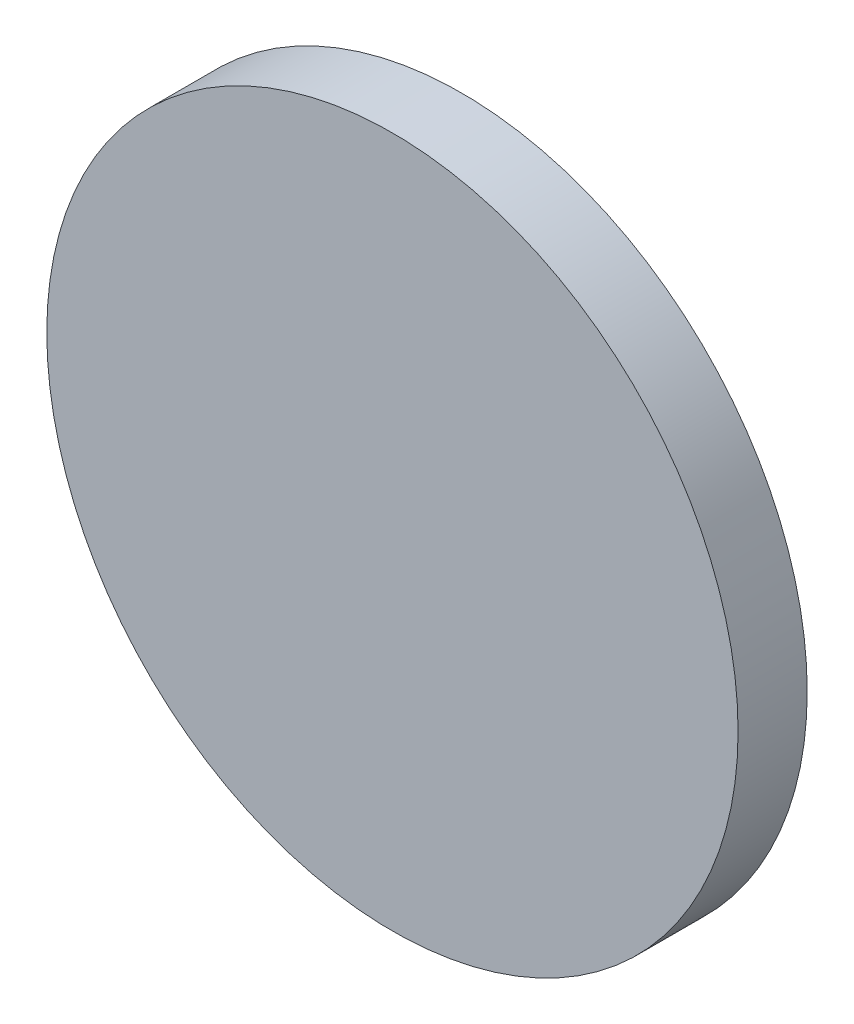
from build123d import *

# Parameters (mm, degrees)
SKETCH_1_R      = 15
EXTRUDE_1_DEPTH = 3


with BuildPart() as part:
    # 草图1 → 凸台-拉伸1 (new body)
    with BuildSketch(Plane.XY):
        Circle(SKETCH_1_R)
    extrude(amount=EXTRUDE_1_DEPTH)


solid = part.part
